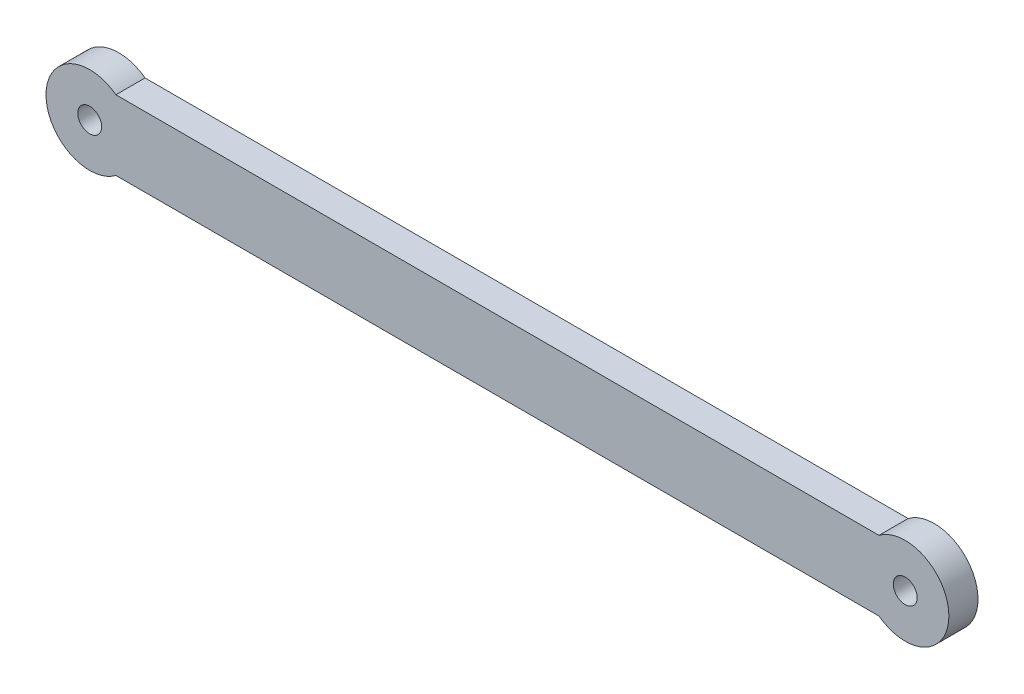
from build123d import *

# Parameters (mm, degrees)
SCHIZZO1_R                   = 2.05
ESTRUSIONE_ESTRUSIONE1_DEPTH = 5


with BuildPart() as part:
    # Schizzo1 → Estrusione-Estrusione1 (new body)
    with BuildSketch(Plane.XY):
        with BuildLine():
            Line((4.5, -6), (135.5, -6))
            ThreePointArc((135.5, -6), (147.5, 0), (135.5, 6))
            Line((135.5, 6), (4.5, 6))
            ThreePointArc((4.5, 6), (-7.5, 0), (4.5, -6))
        make_face()
        Circle(SCHIZZO1_R, mode=Mode.SUBTRACT)
        with Locations((140, 0)):
            Circle(SCHIZZO1_R, mode=Mode.SUBTRACT)
    extrude(amount=ESTRUSIONE_ESTRUSIONE1_DEPTH)


solid = part.part
